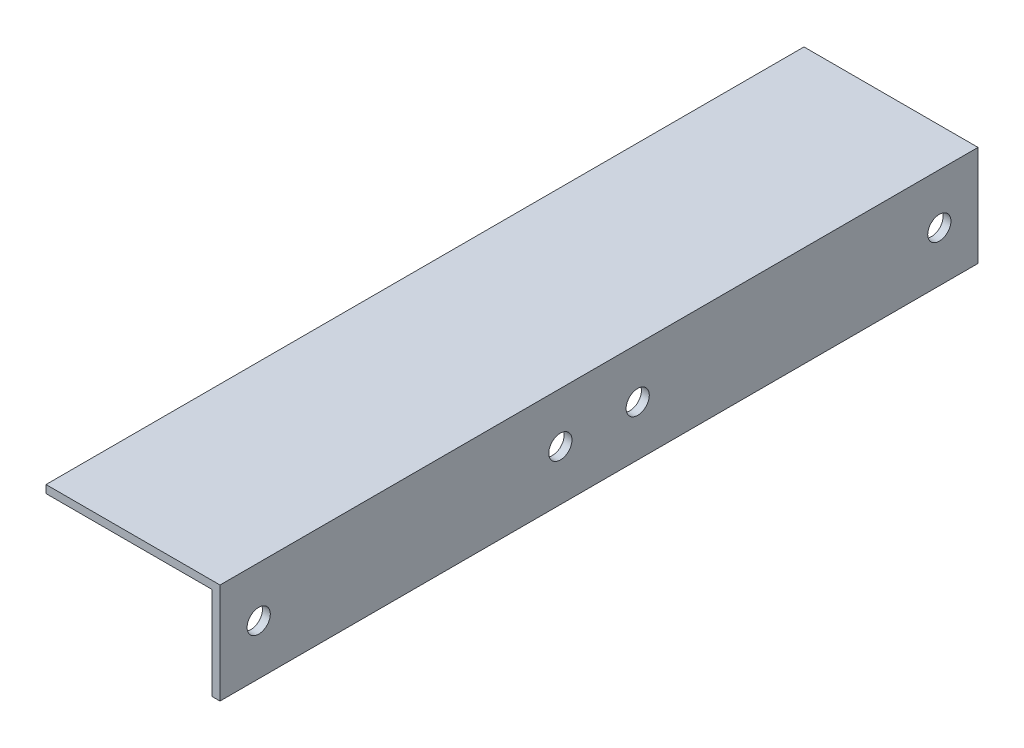
from build123d import *

# Parameters (mm, degrees)
BOSS_EXTRUDE1_DEPTH = 98
SKETCH2_R           = 1.5
CUT_EXTRUDE1_DEPTH  = 40


with BuildPart() as part:
    # Sketch1 → Boss-Extrude1 (new body)
    with BuildSketch(Plane.XY):
        Polygon((0, 0), (-22.5, 0), (-22.5, -1.016), (-1.016, -1.016), (-1.016, -13), (0, -13), align=None)
    extrude(amount=BOSS_EXTRUDE1_DEPTH)

    # Sketch2 → Cut-Extrude1 (cut)
    with BuildSketch(Plane(origin=(0, 0, 0), x_dir=(0, 0, -1), z_dir=(1, 0, 0))):
        with Locations((-93, -6.5)):
            Circle(SKETCH2_R)
        with Locations((-54, -6.5)):
            Circle(SKETCH2_R)
        with Locations((-44, -6.5)):
            Circle(SKETCH2_R)
        with Locations((-5, -6.5)):
            Circle(SKETCH2_R)
    extrude(amount=-CUT_EXTRUDE1_DEPTH, mode=Mode.SUBTRACT)


solid = part.part
